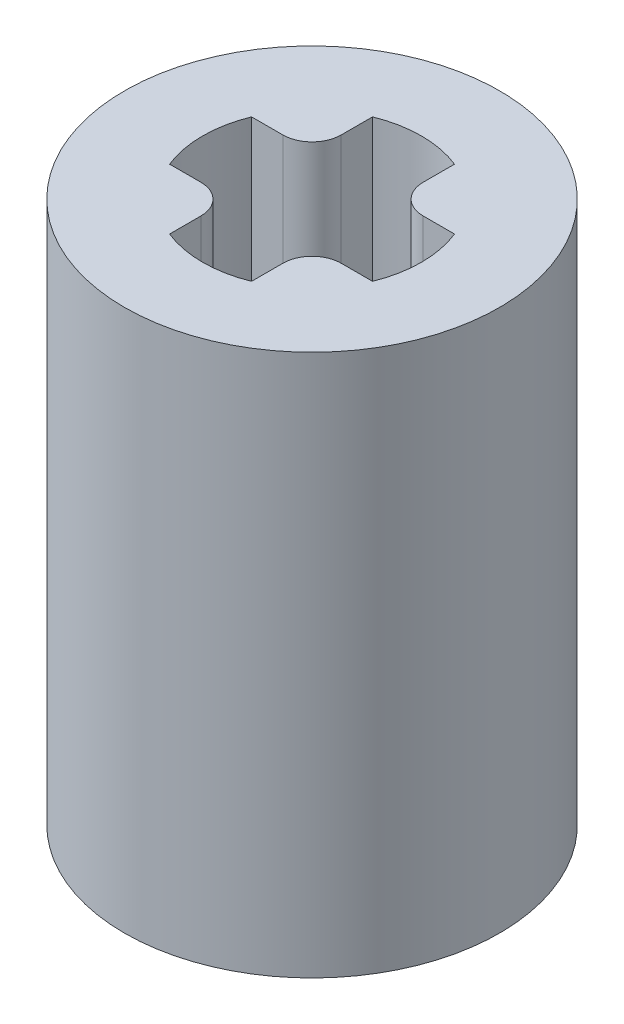
from build123d import *

# Parameters (mm, degrees)
SKETCH1_R           = 4.5
BOSS_EXTRUDE1_DEPTH = 6.5
CUT_EXTRUDE1_DEPTH  = 6
CUT_EXTRUDE2_DEPTH  = 6


with BuildPart() as part:
    # Sketch1 → Boss-Extrude1 (new body, symmetric)
    with BuildSketch(Plane(origin=(0, 0, 0), x_dir=(1, 0, 0), z_dir=(0, 1, 0))):
        Circle(SKETCH1_R)
    extrude(amount=BOSS_EXTRUDE1_DEPTH, both=True)

    # Sketch2 → Cut-Extrude1 (cut)
    with BuildSketch(Plane.XZ.offset(6.5)):
        with BuildLine():
            Line((-1.5865, -2.115124996), (-1.5865, 2.115124996))
            ThreePointArc((-1.5865, 2.115124996), (0, 2.644), (1.5865, 2.115124996))
            Line((1.5865, 2.115124996), (1.5865, -2.115124996))
            ThreePointArc((1.5865, -2.115124996), (0, -2.644), (-1.5865, -2.115124996))
        make_face()
    extrude(amount=-CUT_EXTRUDE1_DEPTH, mode=Mode.SUBTRACT)

    # Sketch3 → Cut-Extrude2 (cut)
    with BuildSketch(Plane(origin=(0, 6.5, 0), x_dir=(1, 0, 0), z_dir=(0, 1, 0))):
        with BuildLine():
            Line((0.983, 2.433995892), (0.983, 1.683))
            ThreePointArc((0.983, 1.683), (1.188025253, 1.188025253), (1.683, 0.983))
            Line((1.683, 0.983), (2.433995892, 0.983))
            ThreePointArc((2.433995892, 0.983), (2.625, 0), (2.433995892, -0.983))
            Line((2.433995892, -0.983), (1.683, -0.983))
            ThreePointArc((1.683, -0.983), (1.188025253, -1.188025253), (0.983, -1.683))
            Line((0.983, -1.683), (0.983, -2.433995892))
            ThreePointArc((0.983, -2.433995892), (0, -2.625), (-0.983, -2.433995892))
            Line((-0.983, -2.433995892), (-0.983, -1.683))
            ThreePointArc((-0.983, -1.683), (-1.188025253, -1.188025253), (-1.683, -0.983))
            Line((-1.683, -0.983), (-2.433995892, -0.983))
            ThreePointArc((-2.433995892, -0.983), (-2.625, 0), (-2.433995892, 0.983))
            Line((-2.433995892, 0.983), (-1.683, 0.983))
            ThreePointArc((-1.683, 0.983), (-1.188025253, 1.188025253), (-0.983, 1.683))
            Line((-0.983, 1.683), (-0.983, 2.433995892))
            ThreePointArc((-0.983, 2.433995892), (0, 2.625), (0.983, 2.433995892))
        make_face()
    extrude(amount=-CUT_EXTRUDE2_DEPTH, mode=Mode.SUBTRACT)


solid = part.part
